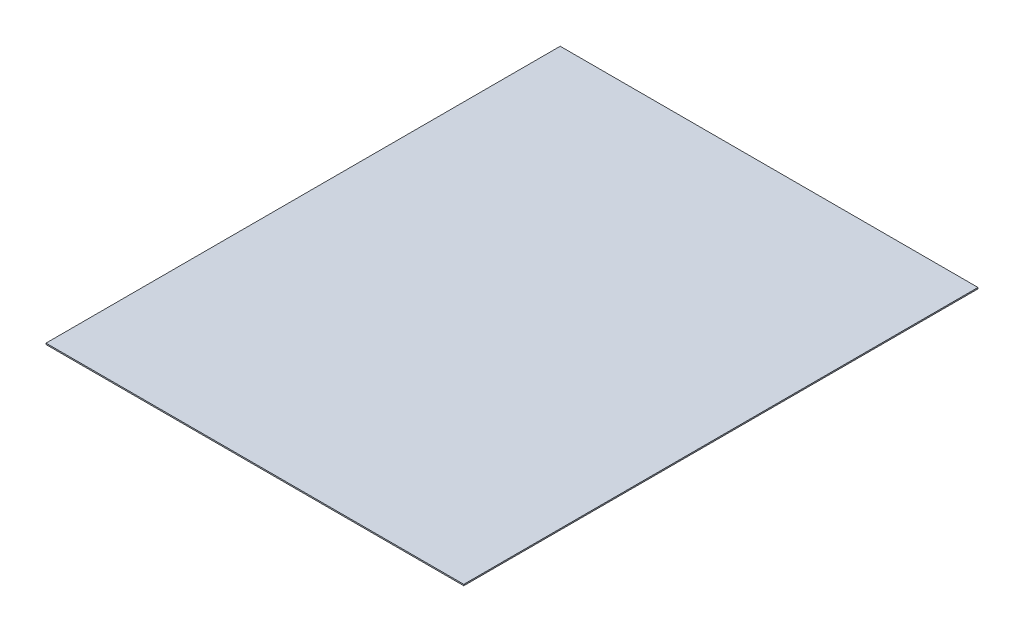
from build123d import *

# Parameters (mm, degrees)
SKETCH1_W           = 990.6
SKETCH1_H           = 1219.2
BOSS_EXTRUDE1_DEPTH = 2.9972


with BuildPart() as part:
    # Sketch1 → Boss-Extrude1 (new body)
    with BuildSketch(Plane(origin=(0, 0, 0), x_dir=(1, 0, 0), z_dir=(0, 1, 0))):
        Rectangle(SKETCH1_W, SKETCH1_H)
    extrude(amount=BOSS_EXTRUDE1_DEPTH)


solid = part.part
